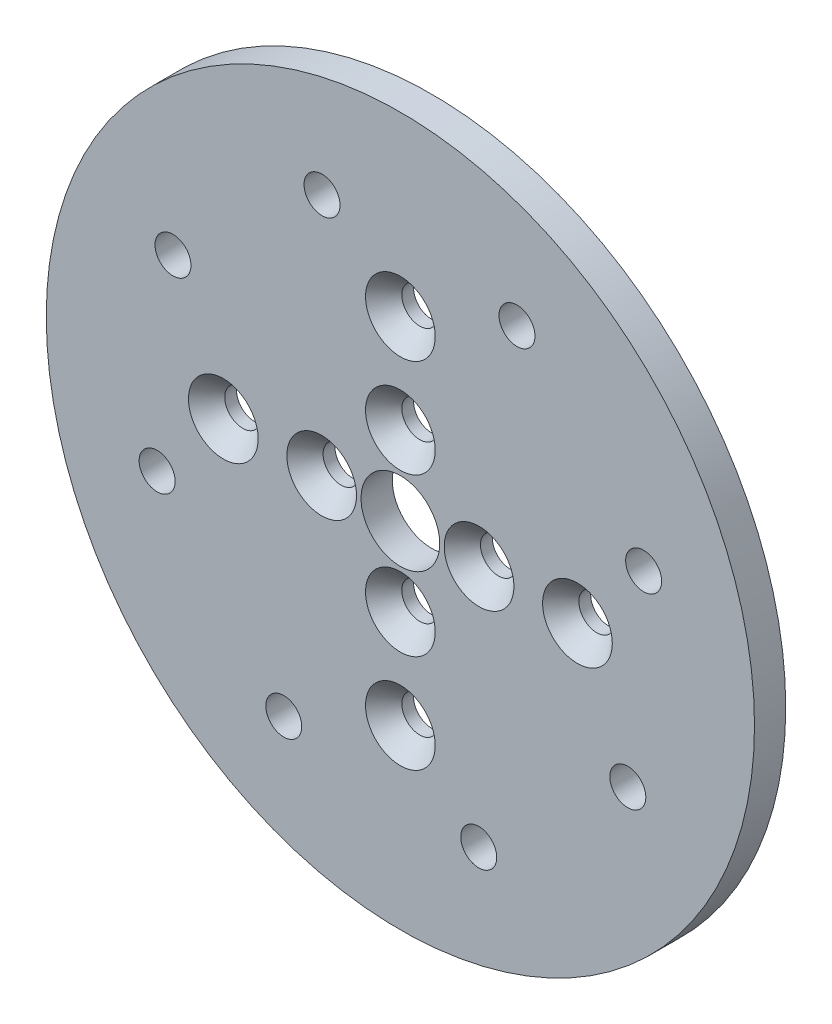
from build123d import *

# Parameters (mm, degrees)
SKETCH1_R                                      = 4
BOSS_EXTRUDE1_DEPTH                            = 3.175
F_6_CLEARANCE_HOLE1_D                          = 3.6576
F_6_CLEARANCE_HOLE1_DEPTH                      = 8
F_6_CLEARANCE_HOLE1_TIP                        = 1.0988539
CSK_FOR_6_FLAT_HEAD_MACHINE_SCREW2_D           = 3.6576
CSK_FOR_6_FLAT_HEAD_MACHINE_SCREW2_DEPTH       = 8
CSK_FOR_6_FLAT_HEAD_MACHINE_SCREW2_CSINK_D     = 7.0866
CSK_FOR_6_FLAT_HEAD_MACHINE_SCREW2_CSINK_ANGLE = 82
CSK_FOR_6_FLAT_HEAD_MACHINE_SCREW2_TIP         = 1.0988539


with BuildPart() as part:
    # Sketch1 → Boss-Extrude1 (new body)
    with BuildSketch(Plane.XY):
        with BuildLine():
            ThreePointArc((-36, 0), (0, -36), (36, 0))
            ThreePointArc((36, 0), (0, 36), (-36, 0))
        make_face()
        Circle(SKETCH1_R, mode=Mode.SUBTRACT)
    extrude(amount=BOSS_EXTRUDE1_DEPTH)

    # 6 Clearance Hole1
    with Locations(Plane(origin=(0, 0, 0), x_dir=(1, 0, 0), z_dir=(0, 0, -1))):
        with Locations((-11.853175458, 23.118447862), (24.728671999, -7.965750509), (11.853175458, -23.118447862), (-7.965750509, -24.728671999), (-23.118447862, -11.853175458), (-24.728671999, 7.965750509), (7.965750509, 24.728671999), (23.118447862, 11.853175458)):
            Hole(F_6_CLEARANCE_HOLE1_D / 2, depth=F_6_CLEARANCE_HOLE1_DEPTH)
            with Locations((0, 0, -(F_6_CLEARANCE_HOLE1_DEPTH + F_6_CLEARANCE_HOLE1_TIP / 2))):  # 118° drill point
                Cone(0, F_6_CLEARANCE_HOLE1_D / 2, F_6_CLEARANCE_HOLE1_TIP, mode=Mode.SUBTRACT)

    # CSK for _6 Flat Head Machine Screw2
    with Locations(Plane(origin=(0, 0, 3.175), x_dir=(-1, 0, 0), z_dir=(0, 0, 1))):
        with Locations((0, -18), (-18, 0), (0, 18), (18, 0), (0, -8), (-8, 0), (0, 8), (8, 0)):
            CounterSinkHole(CSK_FOR_6_FLAT_HEAD_MACHINE_SCREW2_D / 2, CSK_FOR_6_FLAT_HEAD_MACHINE_SCREW2_CSINK_D / 2, depth=CSK_FOR_6_FLAT_HEAD_MACHINE_SCREW2_DEPTH, counter_sink_angle=CSK_FOR_6_FLAT_HEAD_MACHINE_SCREW2_CSINK_ANGLE)
            with Locations((0, 0, -(CSK_FOR_6_FLAT_HEAD_MACHINE_SCREW2_DEPTH + CSK_FOR_6_FLAT_HEAD_MACHINE_SCREW2_TIP / 2))):  # 118° drill point
                Cone(0, CSK_FOR_6_FLAT_HEAD_MACHINE_SCREW2_D / 2, CSK_FOR_6_FLAT_HEAD_MACHINE_SCREW2_TIP, mode=Mode.SUBTRACT)


solid = part.part
